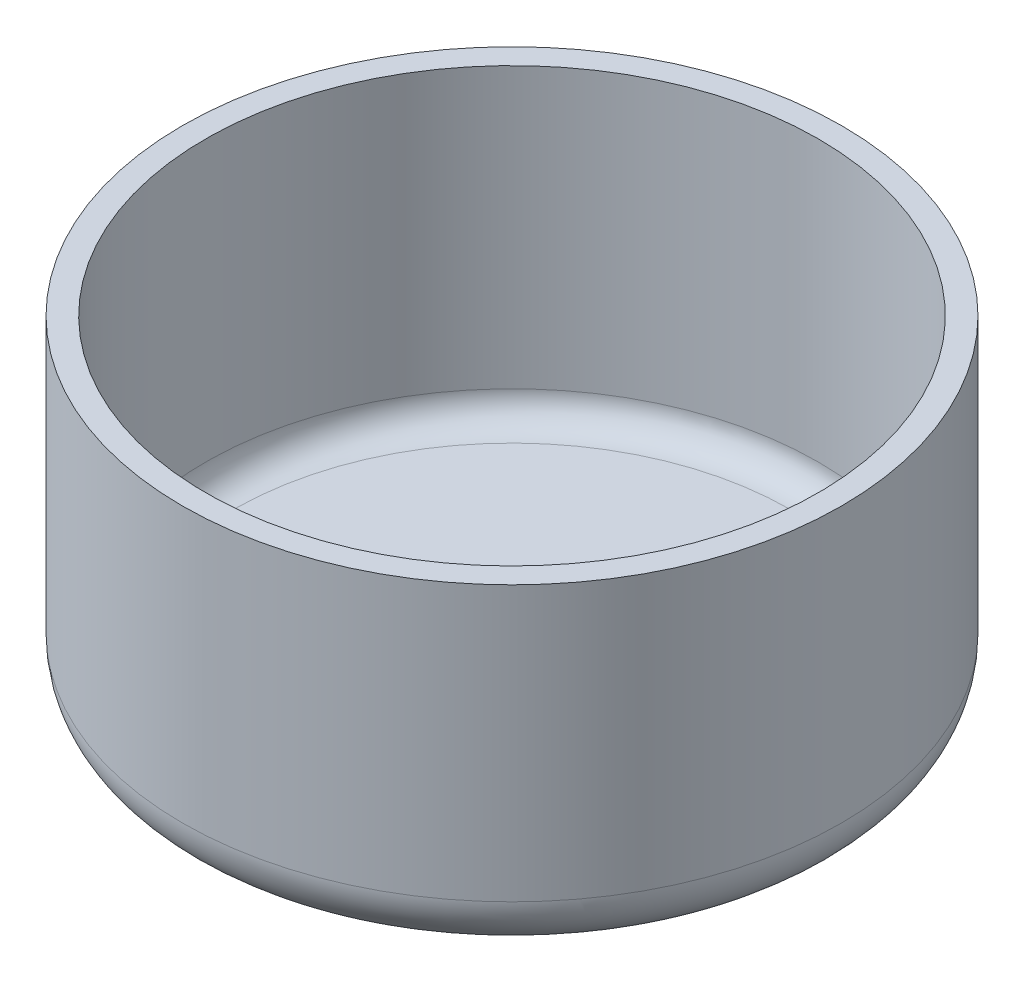
from build123d import *


with BuildPart() as part:
    # Sketch1 → Revolve1 (revolve)
    with BuildSketch(Plane.XY):
        with BuildLine():
            Line((3.302, 0), (9.9314, 0))
            ThreePointArc((9.9314, 0), (11.368240979, 0.595159021), (11.9634, 2.032))
            Line((11.9634, 2.032), (11.9634, 12))
            Line((11.9634, 12), (11.1252, 12))
            Line((11.1252, 12), (11.1252, 1.8382))
            ThreePointArc((11.1252, 1.8382), (10.832306781, 1.131093219), (10.1252, 0.8382))
            Line((10.1252, 0.8382), (3.302, 0.8382))
            Line((3.302, 0.8382), (3.302, 0))
        make_face()
    revolve(axis=Axis((0, 0, 0), (0, 1, 0)))


solid = part.part
